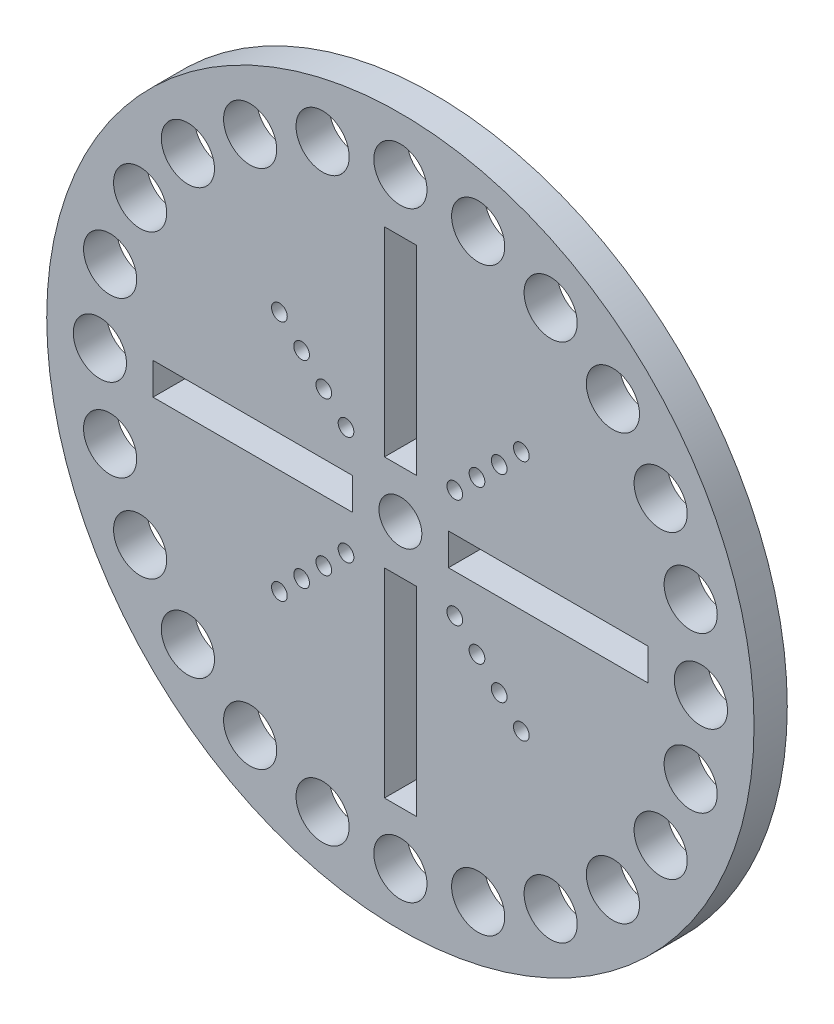
from build123d import *

# Parameters (mm, degrees)
SKETCH1_R           = 33.8
SKETCH1_R_2         = 2.54
SKETCH1_R_3         = 2.05
SKETCH1_R_4         = 0.75
SKETCH1_W           = 3.048
SKETCH1_H           = 19.05
SKETCH1_W_2         = 19.05
SKETCH1_H_2         = 3.048
BOSS_EXTRUDE1_DEPTH = 3.175


with BuildPart() as part:
    # Sketch1 → Boss-Extrude1 (new body)
    with BuildSketch(Plane.XY):
        Circle(SKETCH1_R)
        with Locations((14.36, 24.872249597)):
            Circle(SKETCH1_R_2, mode=Mode.SUBTRACT)
        with Locations((20.308106756, 20.308106756)):
            Circle(SKETCH1_R_2, mode=Mode.SUBTRACT)
        with Locations((24.872249597, 14.36)):
            Circle(SKETCH1_R_2, mode=Mode.SUBTRACT)
        with Locations((27.741389731, 7.433282975)):
            Circle(SKETCH1_R_2, mode=Mode.SUBTRACT)
        with Locations((28.72, 0)):
            Circle(SKETCH1_R_2, mode=Mode.SUBTRACT)
        with Locations((27.741389731, -7.433282975)):
            Circle(SKETCH1_R_2, mode=Mode.SUBTRACT)
        with Locations((24.872249597, -14.36)):
            Circle(SKETCH1_R_2, mode=Mode.SUBTRACT)
        with Locations((20.308106756, -20.308106756)):
            Circle(SKETCH1_R_2, mode=Mode.SUBTRACT)
        with Locations((14.36, -24.872249597)):
            Circle(SKETCH1_R_2, mode=Mode.SUBTRACT)
        with Locations((7.433282975, -27.741389731)):
            Circle(SKETCH1_R_2, mode=Mode.SUBTRACT)
        with Locations((0, -28.72)):
            Circle(SKETCH1_R_2, mode=Mode.SUBTRACT)
        with Locations((-7.433282975, -27.741389731)):
            Circle(SKETCH1_R_2, mode=Mode.SUBTRACT)
        with Locations((-14.36, -24.872249597)):
            Circle(SKETCH1_R_2, mode=Mode.SUBTRACT)
        with Locations((-20.308106756, -20.308106756)):
            Circle(SKETCH1_R_2, mode=Mode.SUBTRACT)
        with Locations((-24.872249597, -14.36)):
            Circle(SKETCH1_R_2, mode=Mode.SUBTRACT)
        with Locations((-27.741389731, -7.433282975)):
            Circle(SKETCH1_R_2, mode=Mode.SUBTRACT)
        with Locations((-28.72, 0)):
            Circle(SKETCH1_R_2, mode=Mode.SUBTRACT)
        with Locations((-27.741389731, 7.433282975)):
            Circle(SKETCH1_R_2, mode=Mode.SUBTRACT)
        with Locations((-24.872249597, 14.36)):
            Circle(SKETCH1_R_2, mode=Mode.SUBTRACT)
        with Locations((-20.308106756, 20.308106756)):
            Circle(SKETCH1_R_2, mode=Mode.SUBTRACT)
        with Locations((-14.36, 24.872249597)):
            Circle(SKETCH1_R_2, mode=Mode.SUBTRACT)
        with Locations((-7.433282975, 27.741389731)):
            Circle(SKETCH1_R_2, mode=Mode.SUBTRACT)
        with Locations((0, 28.72)):
            Circle(SKETCH1_R_2, mode=Mode.SUBTRACT)
        with Locations((7.433282975, 27.741389731)):
            Circle(SKETCH1_R_2, mode=Mode.SUBTRACT)
        Circle(SKETCH1_R_3, mode=Mode.SUBTRACT)
        with Locations((11.561195872, 11.561195872)):
            Circle(SKETCH1_R_4, mode=Mode.SUBTRACT)
        with Locations((9.439875529, 9.439875529)):
            Circle(SKETCH1_R_4, mode=Mode.SUBTRACT)
        with Locations((7.318555185, 7.318555185)):
            Circle(SKETCH1_R_4, mode=Mode.SUBTRACT)
        with Locations((5.197234842, 5.197234842)):
            Circle(SKETCH1_R_4, mode=Mode.SUBTRACT)
        with Locations((11.561195872, -11.561195872)):
            Circle(SKETCH1_R_4, mode=Mode.SUBTRACT)
        with Locations((9.439875529, -9.439875529)):
            Circle(SKETCH1_R_4, mode=Mode.SUBTRACT)
        with Locations((7.318555185, -7.318555185)):
            Circle(SKETCH1_R_4, mode=Mode.SUBTRACT)
        with Locations((5.197234842, -5.197234842)):
            Circle(SKETCH1_R_4, mode=Mode.SUBTRACT)
        with Locations((-11.561195872, -11.561195872)):
            Circle(SKETCH1_R_4, mode=Mode.SUBTRACT)
        with Locations((-9.439875529, -9.439875529)):
            Circle(SKETCH1_R_4, mode=Mode.SUBTRACT)
        with Locations((-7.318555185, -7.318555185)):
            Circle(SKETCH1_R_4, mode=Mode.SUBTRACT)
        with Locations((-5.197234842, -5.197234842)):
            Circle(SKETCH1_R_4, mode=Mode.SUBTRACT)
        with Locations((-11.561195872, 11.561195872)):
            Circle(SKETCH1_R_4, mode=Mode.SUBTRACT)
        with Locations((-9.439875529, 9.439875529)):
            Circle(SKETCH1_R_4, mode=Mode.SUBTRACT)
        with Locations((-7.318555185, 7.318555185)):
            Circle(SKETCH1_R_4, mode=Mode.SUBTRACT)
        with Locations((-5.197234842, 5.197234842)):
            Circle(SKETCH1_R_4, mode=Mode.SUBTRACT)
        with Locations((0, 14.115)):
            Rectangle(SKETCH1_W, SKETCH1_H, mode=Mode.SUBTRACT)
        with Locations((14.115, 0)):
            Rectangle(SKETCH1_W_2, SKETCH1_H_2, mode=Mode.SUBTRACT)
        with Locations((0, -14.115)):
            Rectangle(SKETCH1_W, SKETCH1_H, mode=Mode.SUBTRACT)
        with Locations((-14.115, 0)):
            Rectangle(SKETCH1_W_2, SKETCH1_H_2, mode=Mode.SUBTRACT)
    extrude(amount=BOSS_EXTRUDE1_DEPTH)


solid = part.part
